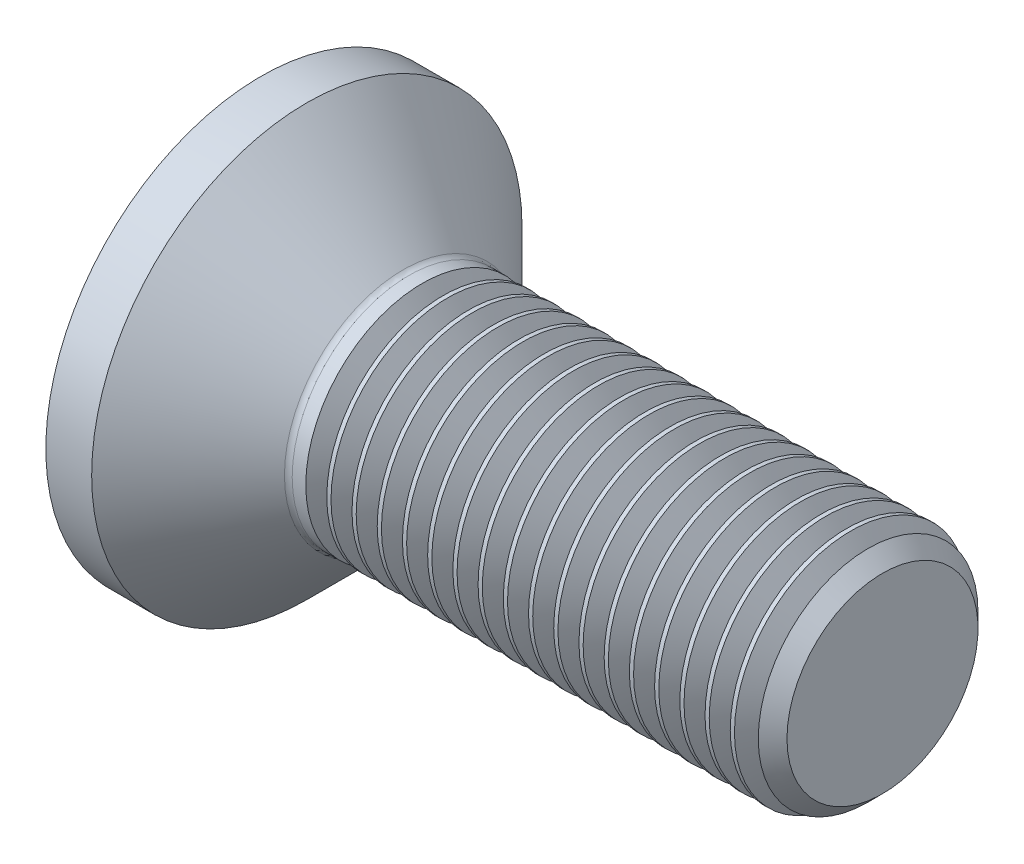
from build123d import *

# Parameters (mm, degrees)
HEXAGONSOCKET_DEPTH = 1.1
HEADFILLET_R        = 0.1
CHAMFER_2_SIZE      = 0.2705
SKETCH4_W           = 5
SKETCH4_H           = 5
LPATTERN10_COUNT    = 18
LPATTERN10_PITCH    = 0.3246


with BuildPart() as part:
    # Sketch1 → Base (revolve)
    with BuildSketch(Plane.XY):
        Polygon((0, 0), (0, 3.36), (1.86, 1.5), (8, 1.5), (8, 0), align=None)
    revolve(axis=Axis((-0.587069181, 0, 0), (1, 0, 0)))

    # Sketch2 → HexagonSocket (cut)
    with BuildSketch(Plane(origin=(0, 0, 0), x_dir=(0, 0, -1), z_dir=(1, 0, 0))):
        Polygon((1.154700538, 0), (0.577350269, 1), (-0.577350269, 1), (-1.154700538, 0), (-0.577350269, -1), (0.577350269, -1), align=None)
    extrude(amount=HEXAGONSOCKET_DEPTH, mode=Mode.SUBTRACT)

    # Sketch3 → Cut-Revolve1 (revolve, cut)
    with BuildSketch(Plane.XY):
        Polygon((1.1, 1), (1.677350269, 0), (1.1, 0), align=None)
    revolve(axis=Axis((-0.439109555, 0, 0), (1, 0, 0)), mode=Mode.SUBTRACT)

    # HeadFillet
    headfillet_edges = [part.edges().sort_by_distance(p)[0] for p in [
        (1.86, -1.5, 0),
    ]]
    fillet(headfillet_edges, radius=HEADFILLET_R)

    # Chamfer 2
    chamfer_2_edges = [part.edges().sort_by_distance(p)[0] for p in [
        (8, -1.5, 0),
    ]]
    chamfer(chamfer_2_edges, length=CHAMFER_2_SIZE)

    # Sketch4 → Cut-Revolve2 (revolve, cut)
    with BuildSketch(Plane(origin=(0, 0, 0), x_dir=(1, 0, 0), z_dir=(0, 1, 0))):
        with Locations((0.5, 5.27)):
            Rectangle(SKETCH4_W, SKETCH4_H)
    revolve(axis=Axis((11.853138686, 0, 0), (-1, 0, 0)), mode=Mode.SUBTRACT)

    # Sketch5 → Cut-Revolve10 (revolve, cut)
    with BuildSketch(Plane.XY):
        Polygon((7.7295, 1.265740128), (7.86475, 1.5), (7.86475, 1.7705), (7.59425, 1.7705), (7.59425, 1.5), align=None)
    cut_revolve10 = revolve(axis=Axis((0, 0, 0), (1, 0, 0)), mode=Mode.SUBTRACT)

    # LPattern10: Cut-Revolve10 ×18
    with Locations(*[(-i * LPATTERN10_PITCH, 0, 0) for i in range(1, LPATTERN10_COUNT)]):
        add(cut_revolve10, mode=Mode.SUBTRACT)


solid = part.part
